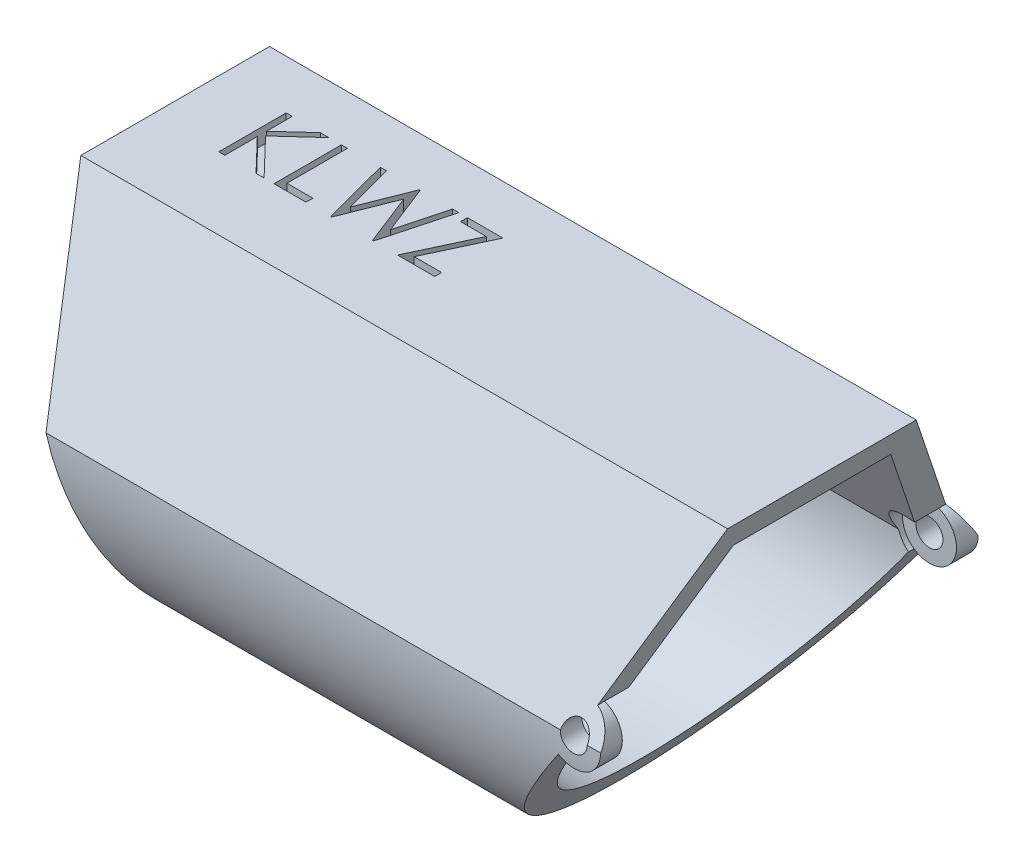
from build123d import *

# Parameters (mm, degrees)
BOSS_EXTRUDE1_DEPTH     = 30.48
SHELL1_T                = -1.27
SKETCH2_R               = 0.635
CUT_EXTRUDE1_DEPTH      = 9.904502457
CUT_EXTRUDE1_DEPTH_BACK = 9.904502457
SKETCH4_R               = 1.27
CUT_EXTRUDE3_DEPTH      = 7.874
CUT_EXTRUDE3_DEPTH_BACK = 7.874
SKETCH5_W               = 1.524
SKETCH5_H               = 2.54
CUT_EXTRUDE5_DEPTH      = 0.508
CUT_EXTRUDE2_DEPTH      = 0.762


with BuildPart() as part:
    # Sketch1 → Boss-Extrude1 (new body)
    with BuildSketch(Plane(origin=(0, 0, 0), x_dir=(0, 0, -1), z_dir=(1, 0, 0))):
        with BuildLine():
            Line((-4.445, 0), (4.445, 0))
            Line((4.445, 0), (8.89, -7.69896584))
            ThreePointArc((8.89, -7.69896584), (0, -17.111468296), (-8.89, -7.69896584))
            Line((-8.89, -7.69896584), (-4.445, 0))
        make_face()
    extrude(amount=BOSS_EXTRUDE1_DEPTH)

    # Shell1
    shell1_openings = [part.faces().sort_by_distance(p)[0] for p in [
        (30.48, -6.202608534, 0),
        (0, -6.202608534, 0),
    ]]
    offset(amount=SHELL1_T, openings=shell1_openings, kind=Kind.INTERSECTION)

    # Sketch2 → Cut-Extrude1 (cut, two sides)
    with BuildSketch(Plane.XY) as cut_extrude1_sk:
        with Locations((27.6778056, -7.69896584)):
            Circle(SKETCH2_R)
        with BuildLine():
            Line((30.48, 0), (28.112171182, -6.505556211))
            ThreePointArc((28.112171182, -6.505556211), (28.804309358, -8.285386578), (26.949363526, -8.739288936))
            Line((26.949363526, -8.739288936), (21.087100426, -17.111468296))
            Line((21.087100426, -17.111468296), (30.48, -17.111468296))
            Line((30.48, -17.111468296), (30.48, 0))
        make_face()
        Polygon((0, 0), (6.228065124, -17.111468296), (0, -17.111468296), align=None)
    extrude(amount=CUT_EXTRUDE1_DEPTH, mode=Mode.SUBTRACT)
    extrude(cut_extrude1_sk.sketch, amount=-CUT_EXTRUDE1_DEPTH_BACK, mode=Mode.SUBTRACT)

    # Sketch4 → Cut-Extrude3 (cut, two sides)
    with BuildSketch(Plane.XY) as cut_extrude3_sk:
        with Locations((27.6778056, -7.69896584)):
            Circle(SKETCH4_R)
    extrude(amount=CUT_EXTRUDE3_DEPTH, mode=Mode.SUBTRACT)
    extrude(cut_extrude3_sk.sketch, amount=-CUT_EXTRUDE3_DEPTH_BACK, mode=Mode.SUBTRACT)

    # Sketch5 → Cut-Extrude5 (cut)
    with BuildSketch(Plane(origin=(0, -17.111468296, 0), x_dir=(1, 0, 0), z_dir=(0, 1, 0))):
        with Locations((6.228065124, 0)):
            Rectangle(SKETCH5_W, SKETCH5_H)
    extrude(amount=CUT_EXTRUDE5_DEPTH, mode=Mode.SUBTRACT)

    # Sketch3 → Cut-Extrude2 (cut)
    with BuildSketch(Plane(origin=(0, 0, 0), x_dir=(1, 0, 0), z_dir=(0, 1, 0))):
        Polygon((3.102574475, 2.126725666), (3.387510372, 2.126725666), (3.387510372, 0.917656155), (4.711063057, 2.126725666), (5.117478321, 2.126725666), (3.557327079, 0.702046179), (5.239593706, -1.048274334), (4.859891182, -1.048274334), (3.387510372, 0.483892132), (3.387510372, -1.048274334), (3.102574475, -1.048274334), align=None)
        Polygon((5.70770268, 2.126725666), (5.992638577, 2.126725666), (5.992638577, -0.722633308), (7.213792424, -0.722633308), (7.213792424, -1.048274334), (5.70770268, -1.048274334), align=None)
        Polygon((7.539433449, 2.126725666), (7.833909611, 2.126725666), (8.455298834, -0.201734871), (9.379432448, 2.126725666), (9.420773594, 2.126725666), (10.327734731, -0.18583443), (10.952304042, 2.126725666), (11.243600116, 2.126725666), (10.387520388, -1.048274334), (10.34681526, -1.048274334), (9.391516783, 1.380040971), (8.424769988, -1.048274334), (8.38406486, -1.048274334), align=None)
        Polygon((11.650651398, 1.80108464), (11.650651398, 2.126725666), (13.319561654, 2.126725666), (11.987740741, -0.722633308), (13.278856526, -0.722633308), (13.278856526, -1.048274334), (11.528536013, -1.048274334), (12.860356927, 1.80108464), align=None)
    extrude(amount=-CUT_EXTRUDE2_DEPTH, mode=Mode.SUBTRACT)


solid = part.part
